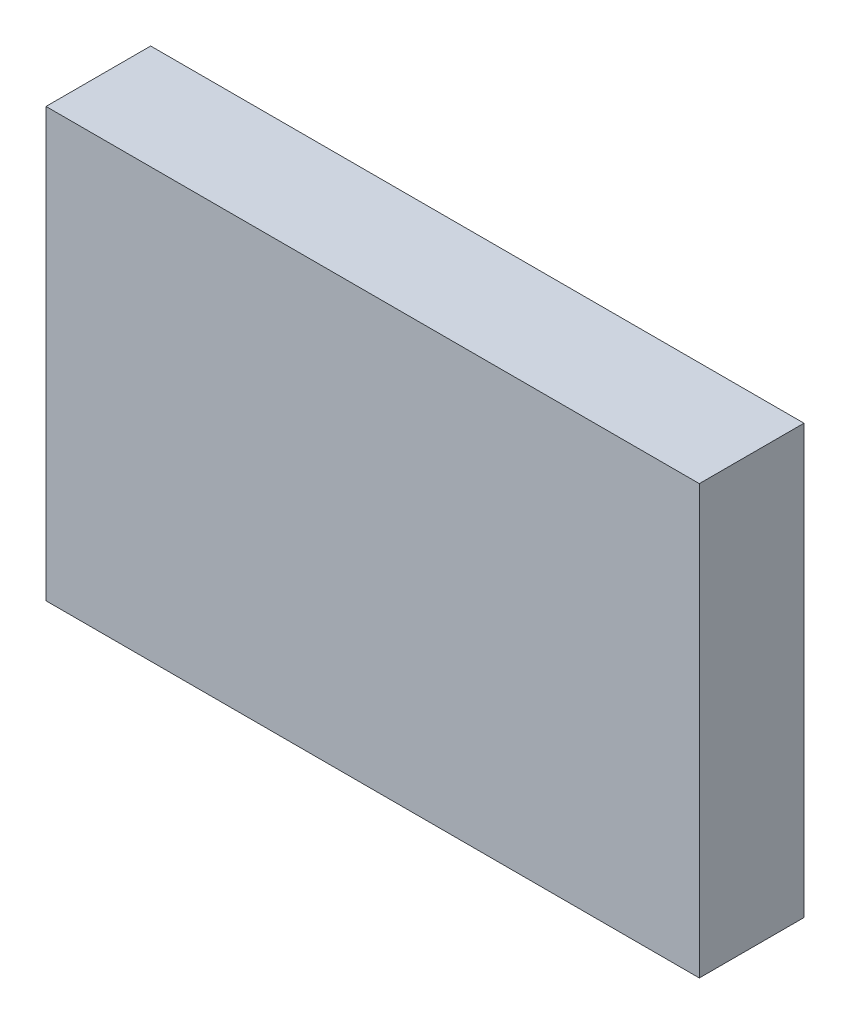
from build123d import *

# Parameters (mm, degrees)
SKETCH1_W           = 206
SKETCH1_H           = 135
BOSS_EXTRUDE1_DEPTH = 33
SKETCH2_W           = 15.5
SKETCH2_H           = 11.5
CUT_EXTRUDE1_DEPTH  = 100
SKETCH3_R           = 3.25
CUT_EXTRUDE2_DEPTH  = 100
SKETCH4_R           = 8.5
CUT_EXTRUDE3_DEPTH  = 100


with BuildPart() as part:
    # Sketch1 → Boss-Extrude1 (new body)
    with BuildSketch(Plane.XY):
        Rectangle(SKETCH1_W, SKETCH1_H)
    extrude(amount=BOSS_EXTRUDE1_DEPTH)

    # Sketch2 → Cut-Extrude1 (cut)
    with BuildSketch(Plane.ZY.offset(103)):
        with Locations((14.75, -51.75)):
            Rectangle(SKETCH2_W, SKETCH2_H)
    extrude(amount=-CUT_EXTRUDE1_DEPTH, mode=Mode.SUBTRACT)

    # Sketch3 → Cut-Extrude2 (cut)
    with BuildSketch(Plane.ZY.offset(103)):
        with Locations((16.75, -15.25)):
            Circle(SKETCH3_R)
    extrude(amount=-CUT_EXTRUDE2_DEPTH, mode=Mode.SUBTRACT)

    # Sketch4 → Cut-Extrude3 (cut)
    with BuildSketch(Plane.ZY.offset(103)):
        with Locations((16, 19)):
            Circle(SKETCH4_R)
    extrude(amount=-CUT_EXTRUDE3_DEPTH, mode=Mode.SUBTRACT)


solid = part.part
